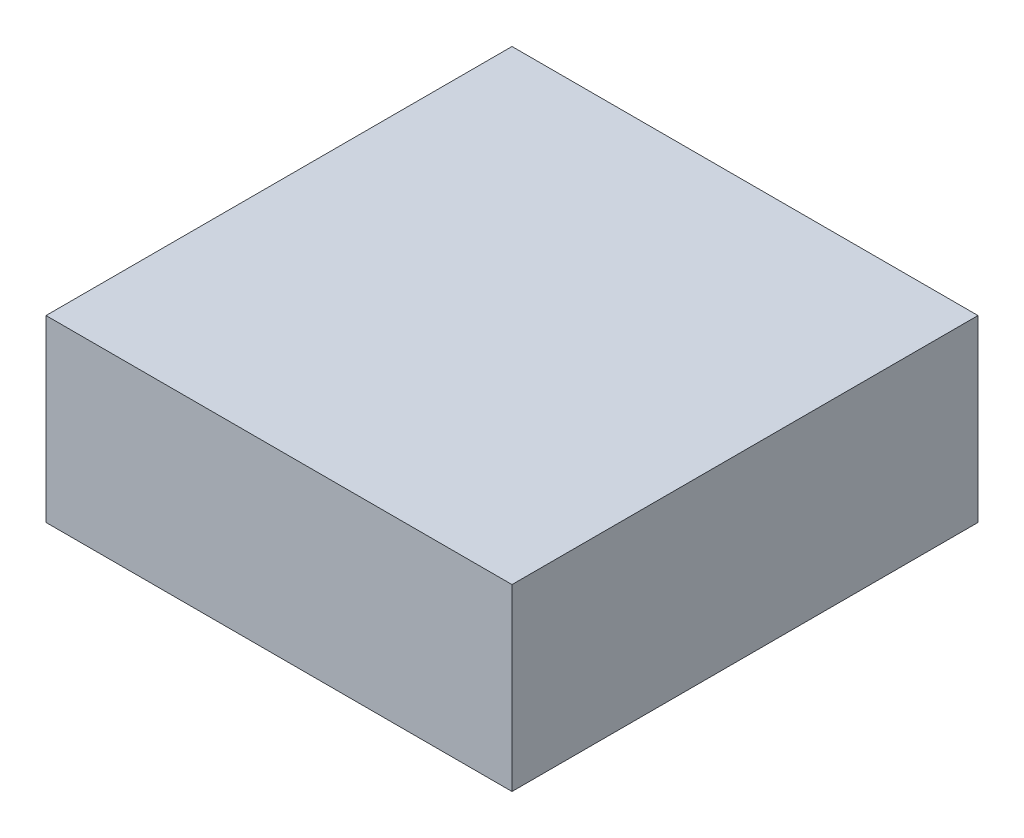
from build123d import *

# Parameters (mm, degrees)
SKETCH1_W           = 130
SKETCH1_H           = 130
BOSS_EXTRUDE1_DEPTH = 50
SKETCH2_W           = 120
SKETCH2_H           = 120
CUT_EXTRUDE1_DEPTH  = 45
SKETCH3_R           = 2.5
BOSS_EXTRUDE2_DEPTH = 5


with BuildPart() as part:
    # Sketch1 → Boss-Extrude1 (new body)
    with BuildSketch(Plane(origin=(0, 0, 0), x_dir=(1, 0, 0), z_dir=(0, 1, 0))):
        with Locations((65, 65)):
            Rectangle(SKETCH1_W, SKETCH1_H)
    extrude(amount=BOSS_EXTRUDE1_DEPTH)

    # Sketch2 → Cut-Extrude1 (cut)
    with BuildSketch(Plane.XZ):
        with Locations((65, -65)):
            Rectangle(SKETCH2_W, SKETCH2_H)
    extrude(amount=-CUT_EXTRUDE1_DEPTH, mode=Mode.SUBTRACT)

    # Sketch3 → Boss-Extrude2 (add)
    with BuildSketch(Plane(origin=(0, 45, 0), x_dir=(-1, 0, 0), z_dir=(0, -1, 0))):
        with Locations((-9, 121)):
            Circle(SKETCH3_R)
        with Locations((-121, 121)):
            Circle(SKETCH3_R)
        with Locations((-9, 9)):
            Circle(SKETCH3_R)
        with Locations((-121, 9)):
            Circle(SKETCH3_R)
    extrude(amount=BOSS_EXTRUDE2_DEPTH)


solid = part.part
